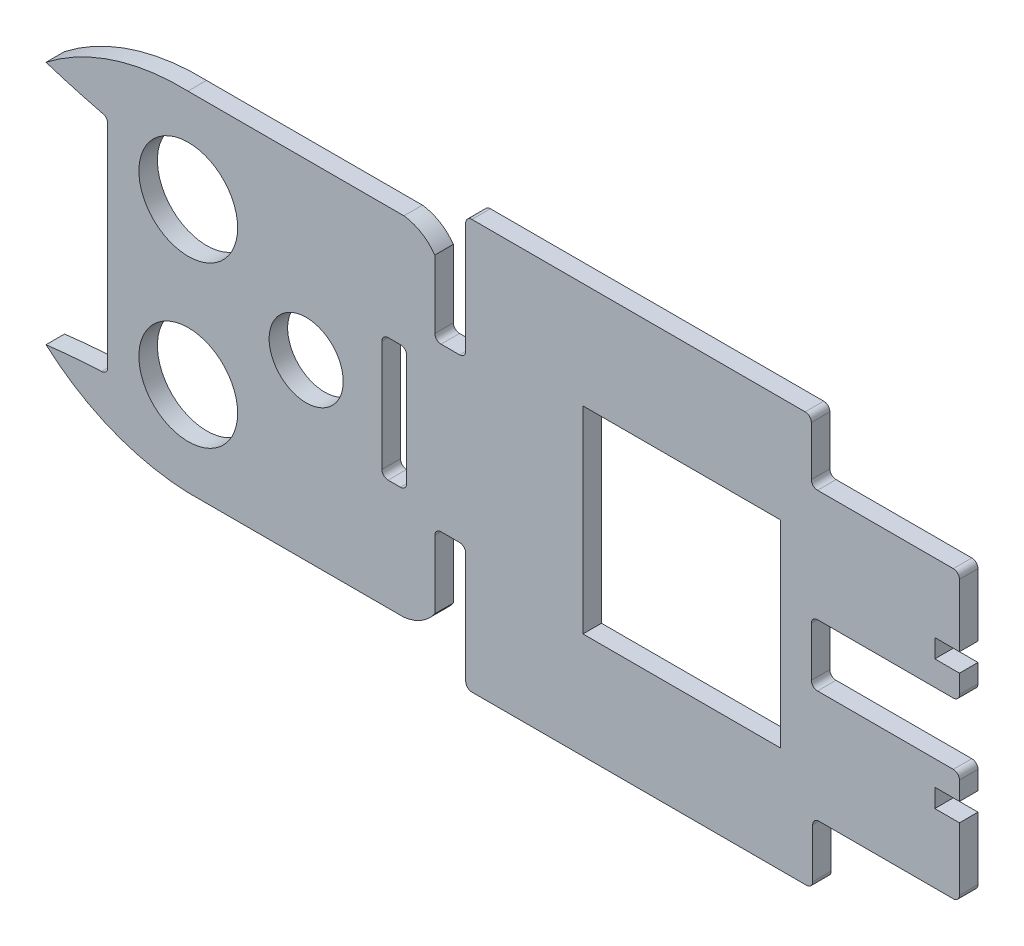
from build123d import *

# Parameters (mm, degrees)
MODEL_R                 = 8
MODEL_R_2               = 6
SALIENTE_EXTRUIR1_DEPTH = 3


with BuildPart() as part:
    # Model → Saliente-Extruir1 (new body)
    with BuildSketch(Plane.XY):
        with BuildLine():
            Line((-29.638958592, -8.6229578), (5.361041408, -8.6229578))
            ThreePointArc((5.361041408, -8.6229578), (8.177920898, -7.651090282), (10.361041408, -5.6229578))
            Line((10.361041408, -5.6229578), (10.361041408, 5.3770422))
            ThreePointArc((10.361041408, 5.3770422), (10.653934627, 6.084148982), (11.361041408, 6.3770422))
            Line((11.361041408, 6.3770422), (14.361041408, 6.3770422))
            ThreePointArc((14.361041408, 6.3770422), (15.068148189, 6.084148982), (15.361041408, 5.3770422))
            Line((15.361041408, 5.3770422), (15.361041408, -12.6229578))
            ThreePointArc((15.361041408, -12.6229578), (15.653934627, -13.330064581), (16.361041408, -13.6229578))
            Line((16.361041408, -13.6229578), (38.295238995, -13.613518735))
            Line((38.295238995, -13.613518735), (70.582767323, -13.6229578))
            ThreePointArc((70.582767323, -13.6229578), (71.289874104, -13.330064581), (71.582767323, -12.6229578))
            Line((71.582767323, -12.6229578), (71.582767323, -4.6229578))
            ThreePointArc((71.582767323, -4.6229578), (71.875660542, -3.915851018), (72.582767323, -3.6229578))
            Line((72.582767323, -3.6229578), (94.361041408, -3.6229578))
            ThreePointArc((94.361041408, -3.6229578), (95.068148189, -3.330064581), (95.361041408, -2.6229578))
            Line((95.361041408, -2.6229578), (95.361041408, 7.540653568))
            Line((95.361041408, 7.540653568), (91.361041408, 7.540653568))
            Line((91.361041408, 7.540653568), (91.361041408, 10.540653568))
            Line((91.361041408, 10.540653568), (95.361041408, 10.540653568))
            Line((95.361041408, 10.540653568), (95.361041408, 13.540653568))
            ThreePointArc((95.361041408, 13.540653568), (95.068148189, 14.247760349), (94.361041408, 14.540653568))
            Line((94.361041408, 14.540653568), (72.361041408, 14.540653568))
            ThreePointArc((72.361041408, 14.540653568), (71.653934627, 14.833546787), (71.361041408, 15.540653568))
            Line((71.361041408, 15.540653568), (71.361041408, 23.540653568))
            ThreePointArc((71.361041408, 23.540653568), (71.653934627, 24.247760349), (72.361041408, 24.540653568))
            Line((72.361041408, 24.540653568), (94.361041408, 24.540653568))
            ThreePointArc((94.361041408, 24.540653568), (95.068148189, 24.833546787), (95.361041408, 25.540653568))
            Line((95.361041408, 25.540653568), (95.361041408, 28.540653568))
            Line((95.361041408, 28.540653568), (91.361041408, 28.540653568))
            Line((91.361041408, 28.540653568), (91.361041408, 31.540653568))
            Line((91.361041408, 31.540653568), (95.361041408, 31.540653568))
            Line((95.361041408, 31.540653568), (95.361041408, 41.704264936))
            ThreePointArc((95.361041408, 41.704264936), (95.068148189, 42.411371717), (94.361041408, 42.704264936))
            Line((94.361041408, 42.704264936), (72.361041408, 42.704264936))
            ThreePointArc((72.361041408, 42.704264936), (71.653934627, 42.997158154), (71.361041408, 43.704264936))
            Line((71.361041408, 43.704264936), (71.361041408, 51.704264936))
            ThreePointArc((71.361041408, 51.704264936), (71.068148189, 52.411371717), (70.361041408, 52.704264936))
            Line((70.361041408, 52.704264936), (45.361041408, 52.704264936))
            Line((45.361041408, 52.704264936), (16.361041408, 52.704264936))
            ThreePointArc((16.361041408, 52.704264936), (15.653934627, 52.411371717), (15.361041408, 51.704264936))
            Line((15.361041408, 51.704264936), (15.361041408, 33.704264936))
            ThreePointArc((15.361041408, 33.704264936), (15.068148189, 32.997158154), (14.361041408, 32.704264936))
            Line((14.361041408, 32.704264936), (11.361041408, 32.704264936))
            ThreePointArc((11.361041408, 32.704264936), (10.653934627, 32.997158154), (10.361041408, 33.704264936))
            Line((10.361041408, 33.704264936), (10.361041408, 44.704264936))
            ThreePointArc((10.361041408, 44.704264936), (8.177920898, 46.732397418), (5.361041408, 47.704264936))
            Line((5.361041408, 47.704264936), (-29.638958592, 47.704264936))
            ThreePointArc((-29.638958592, 47.704264936), (-41.789163023, 45.985500923), (-52.638958592, 40.252826715))
            ThreePointArc((-52.638958592, 40.252826715), (-48.16886463, 38.892993283), (-43.6500909, 37.704897764))
            ThreePointArc((-43.6500909, 37.704897764), (-42.942984119, 37.412004546), (-42.6500909, 36.704897764))
            Line((-42.6500909, 36.704897764), (-42.638958592, 2.3770422))
            ThreePointArc((-42.638958592, 2.3770422), (-42.931851811, 1.669935419), (-43.638958592, 1.3770422))
            ThreePointArc((-43.638958592, 1.3770422), (-48.146181418, 1.085711248), (-52.638958592, 0.622154798))
            ThreePointArc((-52.638958592, 0.622154798), (-41.945677107, -6.007356598), (-29.638958592, -8.6229578))
        make_face()
        with Locations((-29.587538582, 32.540969982)):
            Circle(MODEL_R, mode=Mode.SUBTRACT)
        with Locations((-10.486492238, 19.540969982)):
            Circle(MODEL_R_2, mode=Mode.SUBTRACT)
        with Locations((-29.587538582, 6.540969982)):
            Circle(MODEL_R, mode=Mode.SUBTRACT)
        Polygon((34.361041408, 35.540653568), (34.361041408, 20.040653568), (34.361041408, 3.540653568), (66.361041408, 3.540653568), (66.361041408, 35.540653568), align=None, mode=Mode.SUBTRACT)
        with BuildLine():
            Line((4.790372378, 29.338873837), (2.790372378, 29.338873837))
            ThreePointArc((2.790372378, 29.338873837), (2.083265597, 29.045980618), (1.790372378, 28.338873837))
            Line((1.790372378, 28.338873837), (1.790372378, 10.338873837))
            ThreePointArc((1.790372378, 10.338873837), (2.083265597, 9.631767056), (2.790372378, 9.338873837))
            Line((2.790372378, 9.338873837), (4.790372378, 9.338873837))
            ThreePointArc((4.790372378, 9.338873837), (5.49747916, 9.631767056), (5.790372378, 10.338873837))
            Line((5.790372378, 10.338873837), (5.790372378, 28.338873837))
            ThreePointArc((5.790372378, 28.338873837), (5.49747916, 29.045980618), (4.790372378, 29.338873837))
        make_face(mode=Mode.SUBTRACT)
    extrude(amount=SALIENTE_EXTRUIR1_DEPTH)


solid = part.part
